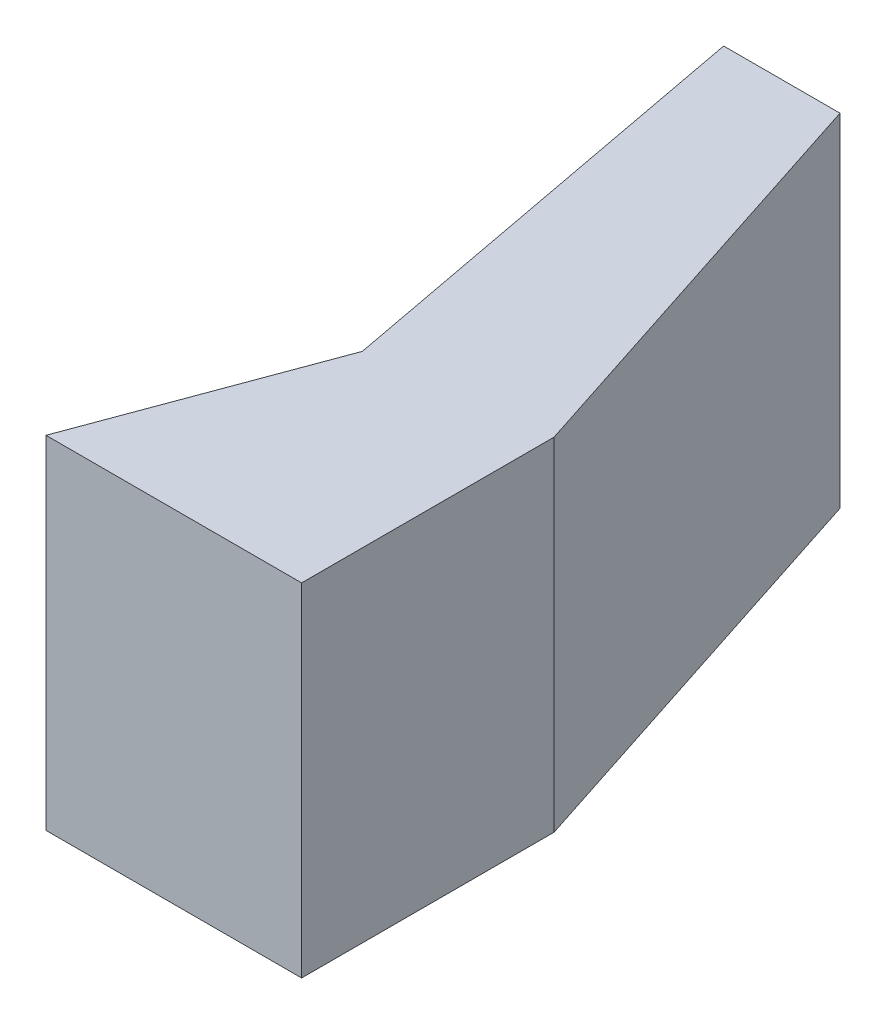
from build123d import *

# Parameters (mm, degrees)
BOSS_EXTRUDE1_DEPTH = 81
BOSS_EXTRUDE2_DEPTH = 2


with BuildPart() as part:
    # Sketch1 → Boss-Extrude1 (new body)
    with BuildSketch(Plane(origin=(0, 0, 0), x_dir=(1, 0, 0), z_dir=(0, 1, 0))):
        Polygon((23.002372201, -47.057873482), (-38.997627799, -47.057873482), (-18.264673723, 8.930513794), (-38.588834845, 116.906230278), (-10.371463192, 116.906230278), (23.002372201, 14.192126518), align=None)
        Polygon((-36.1242874, -45.057873482), (21.002372201, -45.057873482), (21.002372201, 13.875357637), (-11.824548248, 114.906230278), (-36.177255073, 114.906230278), (-16.196659594, 8.755767302), align=None, mode=Mode.SUBTRACT)
    extrude(amount=BOSS_EXTRUDE1_DEPTH)

    # Sketch2 → Boss-Extrude2 (add)
    with BuildSketch(Plane(origin=(0, 81, 0), x_dir=(1, 0, 0), z_dir=(0, 1, 0))):
        Polygon((-38.997627799, -47.057873482), (23.002372201, -47.057873482), (23.002372201, 14.192126518), (-10.371463192, 116.906230278), (-38.588834845, 116.906230278), (-18.264673723, 8.930513794), align=None)
    extrude(amount=BOSS_EXTRUDE2_DEPTH)


solid = part.part
